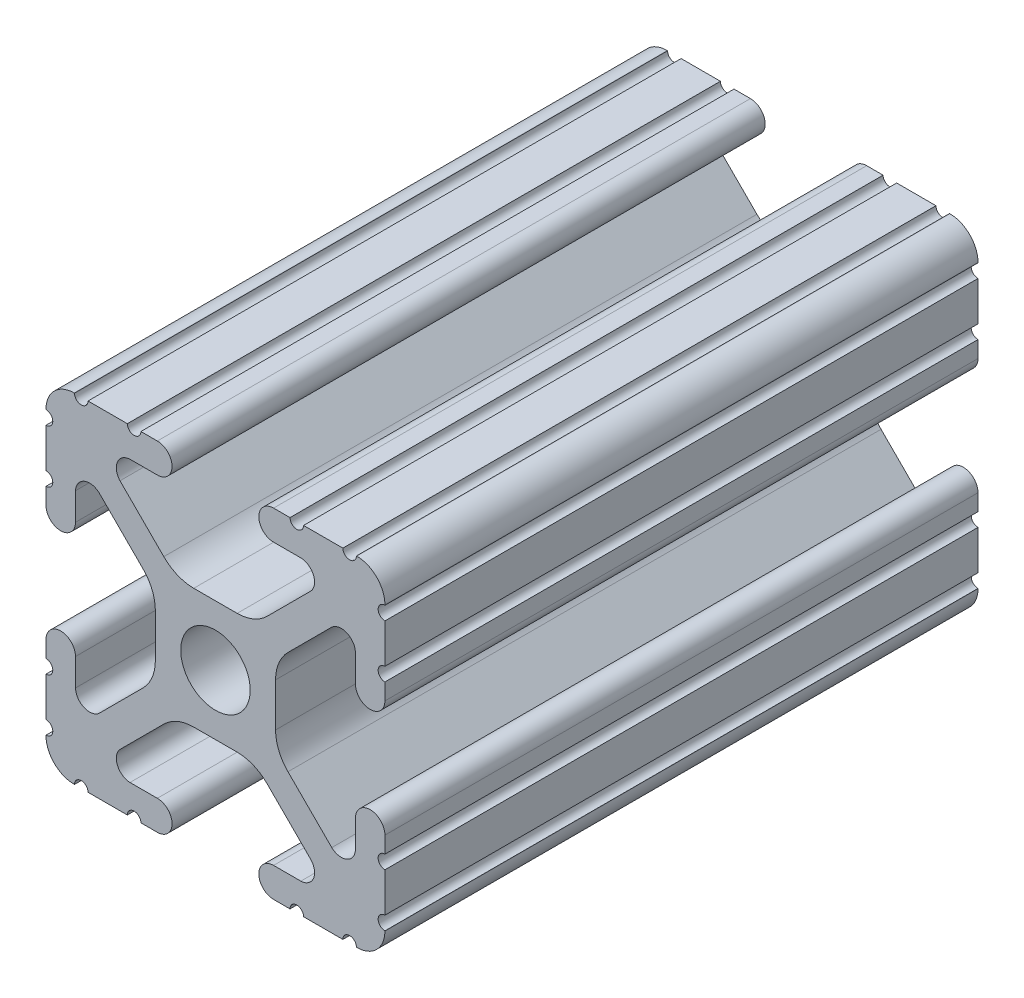
from build123d import *

# Parameters (mm, degrees)
SKETCH1_R      = 2.6035
EXTRUDE1_DEPTH = 44.45


with BuildPart() as part:
    # Sketch1 → Extrude1 (new body)
    with BuildSketch(Plane.XY):
        with BuildLine():
            Line((813.038976674, 579.290424026), (813.038976674, 582.236824026))
            ThreePointArc((813.038976674, 582.236824026), (812.530976674, 582.744824026), (813.038976674, 583.252824026))
            Line((813.038976674, 583.252824026), (813.038976674, 584.484724026))
            ThreePointArc((813.038976674, 584.484724026), (811.934076674, 585.589624026), (810.829176674, 584.484724026))
            Line((810.829176674, 584.484724026), (810.829176674, 582.435874947))
            ThreePointArc((810.829176674, 582.435874947), (810.182743454, 581.495163196), (809.057340701, 581.685644565))
            Line((809.057340701, 581.685644565), (805.773323088, 584.969563516))
            ThreePointArc((805.773323088, 584.969563516), (805.085045004, 585.999619341), (804.843353394, 587.214661271))
            Line((804.843353394, 587.214661271), (804.843353394, 590.467068589))
            ThreePointArc((804.843353394, 590.467068589), (805.085043572, 591.682107061), (805.773317796, 592.712161052))
            Line((805.773317796, 592.712161052), (809.057121325, 595.995881407))
            ThreePointArc((809.057121325, 595.995881407), (810.18544278, 596.185153907), (810.829176674, 595.239352628))
            Line((810.829176674, 595.239352628), (810.829176674, 593.196924026))
            ThreePointArc((810.829176674, 593.196924026), (811.934076674, 592.092024026), (813.038976674, 593.196924026))
            Line((813.038976674, 593.196924026), (813.038976674, 594.428824026))
            ThreePointArc((813.038976674, 594.428824026), (812.530976674, 594.936824026), (813.038976674, 595.444824026))
            Line((813.038976674, 595.444824026), (813.038976674, 598.391224026))
            ThreePointArc((813.038976674, 598.391224026), (812.530976674, 598.899224026), (813.038976674, 599.407224026))
            Line((813.038976674, 599.407224026), (813.038976674, 599.432624026))
            ThreePointArc((813.038976674, 599.432624026), (812.42149919, 600.923346542), (810.930776674, 601.540824026))
            Line((810.930776674, 601.540824026), (810.905376674, 601.540824026))
            ThreePointArc((810.905376674, 601.540824026), (810.397376674, 601.032824026), (809.889376674, 601.540824026))
            Line((809.889376674, 601.540824026), (806.942976674, 601.540824026))
            ThreePointArc((806.942976674, 601.540824026), (806.434976674, 601.032824026), (805.926976674, 601.540824026))
            Line((805.926976674, 601.540824026), (804.695076674, 601.540824026))
            ThreePointArc((804.695076674, 601.540824026), (803.590176674, 600.435924026), (804.695076674, 599.331024026))
            Line((804.695076674, 599.331024026), (806.743925753, 599.331024026))
            ThreePointArc((806.743925753, 599.331024026), (807.684637504, 598.684590806), (807.494156135, 597.559188053))
            Line((807.494156135, 597.559188053), (804.210237184, 594.27517044))
            ThreePointArc((804.210237184, 594.27517044), (803.180181359, 593.586892356), (801.965139429, 593.345200745))
            Line((801.965139429, 593.345200745), (798.712732111, 593.345200745))
            ThreePointArc((798.712732111, 593.345200745), (797.497693639, 593.586890924), (796.467639648, 594.275165148))
            Line((796.467639648, 594.275165148), (793.183919293, 597.558968677))
            ThreePointArc((793.183919293, 597.558968677), (792.994646793, 598.687290132), (793.940448072, 599.331024026))
            Line((793.940448072, 599.331024026), (795.982876674, 599.331024026))
            ThreePointArc((795.982876674, 599.331024026), (797.087776674, 600.435924026), (795.982876674, 601.540824026))
            Line((795.982876674, 601.540824026), (794.750976674, 601.540824026))
            ThreePointArc((794.750976674, 601.540824026), (794.242976674, 601.032824026), (793.734976674, 601.540824026))
            Line((793.734976674, 601.540824026), (790.788576674, 601.540824026))
            ThreePointArc((790.788576674, 601.540824026), (790.280576674, 601.032824026), (789.772576674, 601.540824026))
            Line((789.772576674, 601.540824026), (789.747176674, 601.540824026))
            ThreePointArc((789.747176674, 601.540824026), (788.256454158, 600.923346542), (787.638976674, 599.432624026))
            Line((787.638976674, 599.432624026), (787.638976674, 599.407224026))
            ThreePointArc((787.638976674, 599.407224026), (788.146976674, 598.899224026), (787.638976674, 598.391224026))
            Line((787.638976674, 598.391224026), (787.638976674, 595.444824026))
            ThreePointArc((787.638976674, 595.444824026), (788.146976674, 594.936824026), (787.638976674, 594.428824026))
            Line((787.638976674, 594.428824026), (787.638976674, 593.196924026))
            ThreePointArc((787.638976674, 593.196924026), (788.743876674, 592.092024026), (789.848776674, 593.196924026))
            Line((789.848776674, 593.196924026), (789.848776674, 595.245773105))
            ThreePointArc((789.848776674, 595.245773105), (790.495209894, 596.186484856), (791.620612647, 595.996003487))
            Line((791.620612647, 595.996003487), (794.90463026, 592.712084536))
            ThreePointArc((794.90463026, 592.712084536), (795.592908344, 591.682028711), (795.834599954, 590.466986781))
            Line((795.834599954, 590.466986781), (795.834599954, 587.214579463))
            ThreePointArc((795.834599954, 587.214579463), (795.592909776, 585.999540991), (794.904635552, 584.969487))
            Line((794.904635552, 584.969487), (791.620832022, 581.685766645))
            ThreePointArc((791.620832022, 581.685766645), (790.492510568, 581.496494145), (789.848776674, 582.442295424))
            Line((789.848776674, 582.442295424), (789.848776674, 584.484724026))
            ThreePointArc((789.848776674, 584.484724026), (788.743876674, 585.589624026), (787.638976674, 584.484724026))
            Line((787.638976674, 584.484724026), (787.638976674, 583.252824026))
            ThreePointArc((787.638976674, 583.252824026), (788.146976674, 582.744824026), (787.638976674, 582.236824026))
            Line((787.638976674, 582.236824026), (787.638976674, 579.290424026))
            ThreePointArc((787.638976674, 579.290424026), (788.146976674, 578.782424026), (787.638976674, 578.274424026))
            Line((787.638976674, 578.274424026), (787.638976674, 578.249024026))
            ThreePointArc((787.638976674, 578.249024026), (788.256454158, 576.75830151), (789.747176674, 576.140824026))
            Line((789.747176674, 576.140824026), (789.772576674, 576.140824026))
            ThreePointArc((789.772576674, 576.140824026), (790.280576674, 576.648824026), (790.788576674, 576.140824026))
            Line((790.788576674, 576.140824026), (793.734976674, 576.140824026))
            ThreePointArc((793.734976674, 576.140824026), (794.242976674, 576.648824026), (794.750976674, 576.140824026))
            Line((794.750976674, 576.140824026), (795.982876674, 576.140824026))
            ThreePointArc((795.982876674, 576.140824026), (797.087776674, 577.245724026), (795.982876674, 578.350624026))
            Line((795.982876674, 578.350624026), (793.934027595, 578.350624026))
            ThreePointArc((793.934027595, 578.350624026), (792.993315844, 578.997057246), (793.183797213, 580.122459999))
            Line((793.183797213, 580.122459999), (796.467716164, 583.406477612))
            ThreePointArc((796.467716164, 583.406477612), (797.497771989, 584.094755696), (798.712813919, 584.336447306))
            Line((798.712813919, 584.336447306), (801.965221237, 584.336447306))
            ThreePointArc((801.965221237, 584.336447306), (803.180259709, 584.094757128), (804.2103137, 583.406482904))
            Line((804.2103137, 583.406482904), (807.494034055, 580.122679374))
            ThreePointArc((807.494034055, 580.122679374), (807.683306555, 578.99435792), (806.737505276, 578.350624026))
            Line((806.737505276, 578.350624026), (804.695076674, 578.350624026))
            ThreePointArc((804.695076674, 578.350624026), (803.590176674, 577.245724026), (804.695076674, 576.140824026))
            Line((804.695076674, 576.140824026), (805.926976674, 576.140824026))
            ThreePointArc((805.926976674, 576.140824026), (806.434976674, 576.648824026), (806.942976674, 576.140824026))
            Line((806.942976674, 576.140824026), (809.889376674, 576.140824026))
            ThreePointArc((809.889376674, 576.140824026), (810.397376674, 576.648824026), (810.905376674, 576.140824026))
            Line((810.905376674, 576.140824026), (810.930776674, 576.140824026))
            ThreePointArc((810.930776674, 576.140824026), (812.42149919, 576.75830151), (813.038976674, 578.249024026))
            Line((813.038976674, 578.249024026), (813.038976674, 578.274424026))
            ThreePointArc((813.038976674, 578.274424026), (812.530976674, 578.782424026), (813.038976674, 579.290424026))
        make_face()
        with Locations((800.338976674, 588.840824026)):
            Circle(SKETCH1_R, mode=Mode.SUBTRACT)
    extrude(amount=-EXTRUDE1_DEPTH)


solid = part.part
